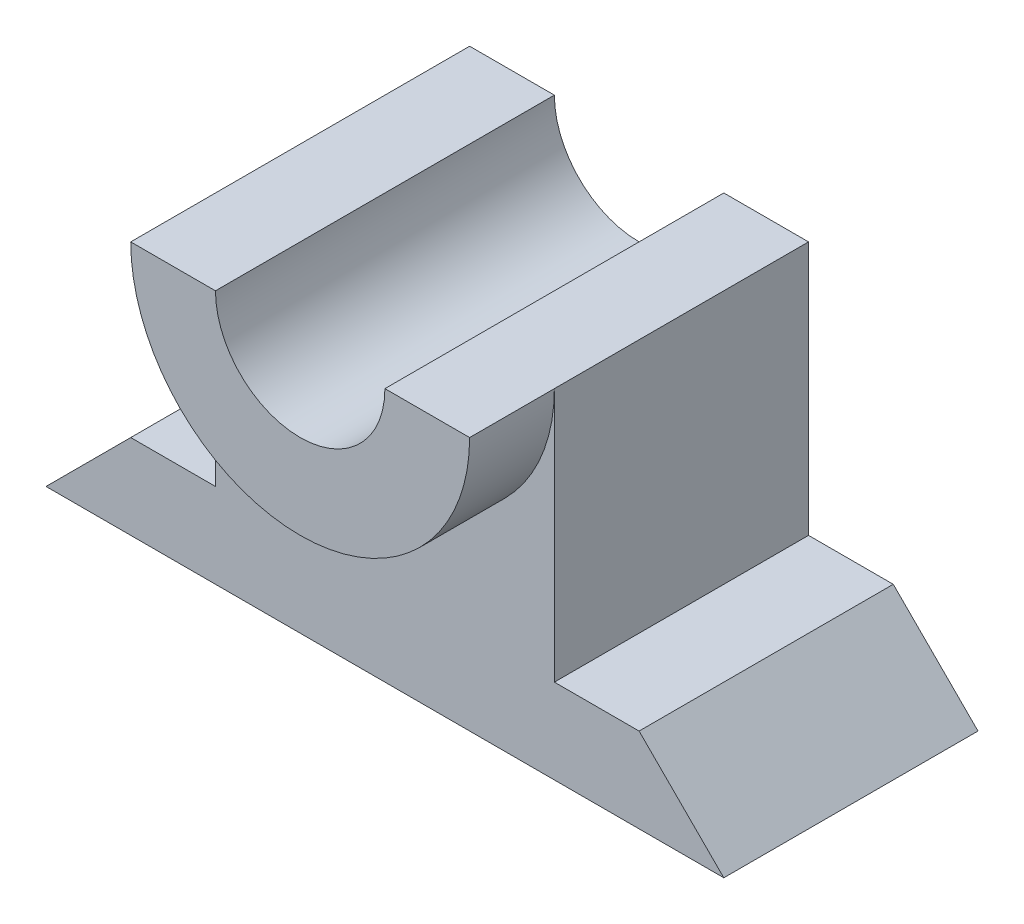
from build123d import *

# Parameters (mm, degrees)
EXTRUDE_1_DEPTH     = 15
EXTRUDE_2_DEPTH     = 20
CUT_EXTRUDE_1_DEPTH = 20


with BuildPart() as part:
    # 草圖1 → 填料-伸長1 (new body)
    with BuildSketch(Plane.XY):
        Polygon((0, 0), (20, 0), (15, 5), (10, 5), (10, 20), (0, 20), align=None)
    extrude_1 = extrude(amount=EXTRUDE_1_DEPTH)

    # 草圖2 → 填料-伸長2 (add)
    with BuildSketch(Plane.XY):
        with BuildLine():
            ThreePointArc((0, 10), (7.071067812, 12.928932188), (10, 20))
            Line((10, 20), (5, 20))
            ThreePointArc((5, 20), (3.535533906, 16.464466094), (0, 15))
            Line((0, 15), (0, 10))
        make_face()
    extrude_2 = extrude(amount=EXTRUDE_2_DEPTH)

    # 草圖2<3> → 除料-伸長1 (cut)
    with BuildSketch(Plane.XY):
        with BuildLine():
            ThreePointArc((0, 15), (3.535533906, 16.464466094), (5, 20))
            Line((5, 20), (0, 20))
            Line((0, 20), (0, 15))
        make_face()
    cut_extrude_1 = extrude(amount=CUT_EXTRUDE_1_DEPTH, mode=Mode.SUBTRACT)

    # 鏡射1: 填料-伸長1, 填料-伸長2, 除料-伸長1 across plane
    add(extrude_1.mirror(Plane(origin=(0, 0, 0), x_dir=(0, 0, 1), z_dir=(1, 0, 0))))
    add(extrude_2.mirror(Plane(origin=(0, 0, 0), x_dir=(0, 0, 1), z_dir=(1, 0, 0))))
    add(cut_extrude_1.mirror(Plane(origin=(0, 0, 0), x_dir=(0, 0, 1), z_dir=(1, 0, 0))), mode=Mode.SUBTRACT)


solid = part.part
